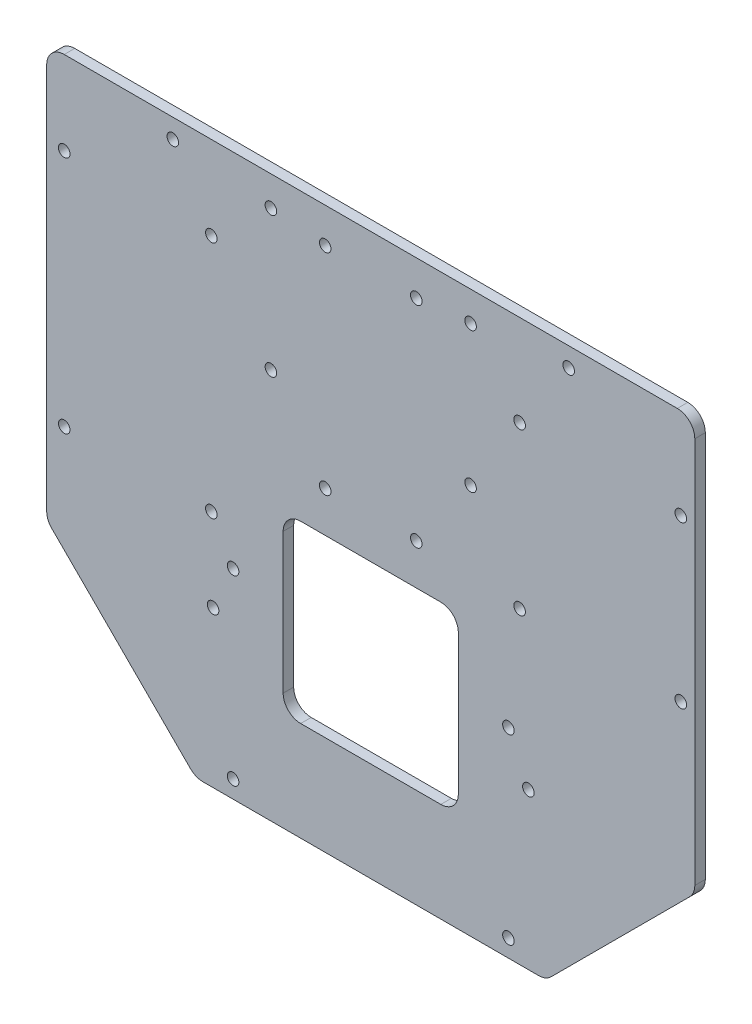
from build123d import *

# Parameters (mm, degrees)
EXTRUDE_1_DEPTH     = 3
SKETCH_2_R          = 1.65
CUT_EXTRUDE_1_DEPTH = 10
SKETCH_3_R          = 1.65
CUT_EXTRUDE_2_DEPTH = 10
SKETCH_4_R          = 1.65
CUT_EXTRUDE_3_DEPTH = 10
SKETCH_5_R          = 1.65
CUT_EXTRUDE_4_DEPTH = 10
SKETCH_6_R          = 1.65
CUT_EXTRUDE_5_DEPTH = 10
SKETCH_7_R          = 1.65
CUT_EXTRUDE_6_DEPTH = 10
CUT_EXTRUDE_7_DEPTH = 10
FILLET_1_R          = 5


with BuildPart() as part:
    # 草图1 → 凸台-拉伸1 (new body)
    with BuildSketch(Plane.XY):
        with BuildLine():
            Line((-87.5, 103.859649123), (87.5, 103.859649123))
            ThreePointArc((87.5, 103.859649123), (91.035533906, 102.395183029), (92.5, 98.859649123))
            Line((92.5, 98.859649123), (92.5, -13.640350877))
            Line((92.5, -13.640350877), (50, -56.140350877))
            Line((50, -56.140350877), (-50, -56.140350877))
            Line((-50, -56.140350877), (-92.5, -13.640350877))
            Line((-92.5, -13.640350877), (-92.5, 98.859649123))
            ThreePointArc((-92.5, 98.859649123), (-91.035533906, 102.395183029), (-87.5, 103.859649123))
        make_face()
    extrude(amount=EXTRUDE_1_DEPTH)

    # 草图2 → 切除-拉伸1 (cut)
    with BuildSketch(Plane.XY.offset(3)):
        with Locations((-28.5, 95.359649123)):
            Circle(SKETCH_2_R)
        with Locations((28.5, 95.359649123)):
            Circle(SKETCH_2_R)
        with Locations((-28.5, 55.359649123)):
            Circle(SKETCH_2_R)
        with Locations((28.5, 55.359649123)):
            Circle(SKETCH_2_R)
    extrude(amount=-CUT_EXTRUDE_1_DEPTH, mode=Mode.SUBTRACT)

    # 草图3 → 切除-拉伸2 (cut)
    with BuildSketch(Plane.XY.offset(3)):
        with Locations((-87.5, 80.059649123)):
            Circle(SKETCH_3_R)
        with Locations((-45.5, 80.059649123)):
            Circle(SKETCH_3_R)
        with Locations((-87.5, 11.859649123)):
            Circle(SKETCH_3_R)
        with Locations((-45.5, 11.859649123)):
            Circle(SKETCH_3_R)
    extrude(amount=-CUT_EXTRUDE_2_DEPTH, mode=Mode.SUBTRACT)

    # 草图4 → 切除-拉伸3 (cut)
    with BuildSketch(Plane.XY.offset(3)):
        with Locations((42.5, 77.859649123)):
            Circle(SKETCH_4_R)
        with Locations((88.5, 77.859649123)):
            Circle(SKETCH_4_R)
        with Locations((42.5, 31.859649123)):
            Circle(SKETCH_4_R)
        with Locations((88.5, 31.859649123)):
            Circle(SKETCH_4_R)
    extrude(amount=-CUT_EXTRUDE_3_DEPTH, mode=Mode.SUBTRACT)

    # 草图5 → 切除-拉伸4 (cut)
    with BuildSketch(Plane.XY.offset(3)):
        with Locations((-39.3, 0.859649123)):
            Circle(SKETCH_5_R)
        with Locations((39.3, 0.859649123)):
            Circle(SKETCH_5_R)
        with Locations((-39.3, -51.140350877)):
            Circle(SKETCH_5_R)
        with Locations((39.3, -51.140350877)):
            Circle(SKETCH_5_R)
    extrude(amount=-CUT_EXTRUDE_4_DEPTH, mode=Mode.SUBTRACT)

    # 草图6 → 切除-拉伸5 (cut)
    with BuildSketch(Plane.XY.offset(3)):
        with Locations((-56.5, 98.359649123)):
            Circle(SKETCH_6_R)
        with Locations((56.5, 98.359649123)):
            Circle(SKETCH_6_R)
        with Locations((-45, -11.640350877)):
            Circle(SKETCH_6_R)
        with Locations((45, -11.640350877)):
            Circle(SKETCH_6_R)
    extrude(amount=-CUT_EXTRUDE_5_DEPTH, mode=Mode.SUBTRACT)

    # 草图7 → 切除-拉伸6 (cut)
    with BuildSketch(Plane.XY.offset(3)):
        with Locations((-13, 93.859649123)):
            Circle(SKETCH_7_R)
        with Locations((13, 93.859649123)):
            Circle(SKETCH_7_R)
        with Locations((13, 33.859649123)):
            Circle(SKETCH_7_R)
        with Locations((-13, 33.859649123)):
            Circle(SKETCH_7_R)
    extrude(amount=-CUT_EXTRUDE_6_DEPTH, mode=Mode.SUBTRACT)

    # 草图8 → 切除-拉伸7 (cut)
    with BuildSketch(Plane.XY.offset(3)):
        with BuildLine():
            Line((-20, 22.217358158), (20, 22.217358158))
            ThreePointArc((20, 22.217358158), (23.535533906, 20.752892063), (25, 17.217358158))
            Line((25, 17.217358158), (25, -22.782641842))
            ThreePointArc((25, -22.782641842), (23.535533906, -26.318175748), (20, -27.782641842))
            Line((20, -27.782641842), (-20, -27.782641842))
            ThreePointArc((-20, -27.782641842), (-23.535533906, -26.318175748), (-25, -22.782641842))
            Line((-25, -22.782641842), (-25, 17.217358158))
            ThreePointArc((-25, 17.217358158), (-23.535533906, 20.752892063), (-20, 22.217358158))
        make_face()
    extrude(amount=-CUT_EXTRUDE_7_DEPTH, mode=Mode.SUBTRACT)

    # 圆角1
    fillet_1_edges = [part.edges().sort_by_distance(p)[0] for p in [
        (-92.5, -13.640350877, 1.5),
        (92.5, -13.640350877, 1.5),
        (50, -56.140350877, 1.5),
        (-50, -56.140350877, 1.5),
    ]]
    fillet(fillet_1_edges, radius=FILLET_1_R)


solid = part.part
